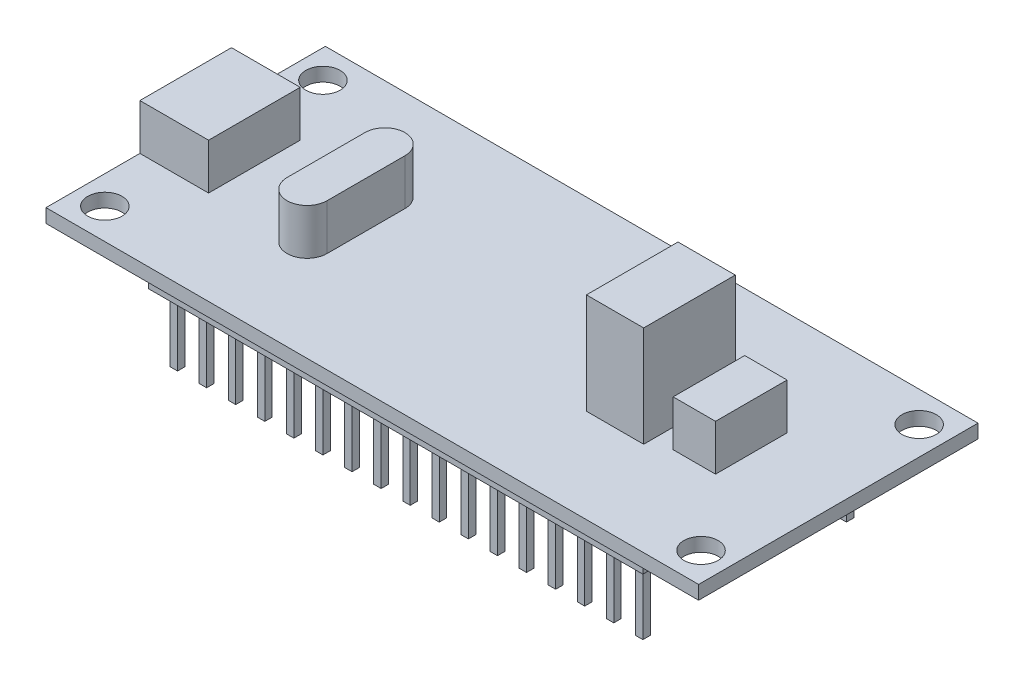
from build123d import *

# Parameters (mm, degrees)
SKETCH1_W           = 57
SKETCH1_H           = 24.4
BOSS_EXTRUDE1_DEPTH = 1.2
SKETCH2_R           = 1.5
CUT_EXTRUDE1_DEPTH  = 2.2
SKETCH3_W           = 6
SKETCH3_H           = 8
BOSS_EXTRUDE2_DEPTH = 4
BOSS_EXTRUDE3_DEPTH = 4
SKETCH5_W           = 5
SKETCH5_H           = 8
BOSS_EXTRUDE4_DEPTH = 8.8
SKETCH6_W           = 3.7
SKETCH6_H           = 6.25
BOSS_EXTRUDE5_DEPTH = 4
SKETCH7_W           = 43.18
SKETCH7_H           = 2.54
BOSS_EXTRUDE6_DEPTH = 2.5
SKETCH8_W           = 0.65
SKETCH8_H           = 0.65
BOSS_EXTRUDE7_DEPTH = 5.9


with BuildPart() as part:
    # Sketch1 → Boss-Extrude1 (new body)
    with BuildSketch(Plane(origin=(0, 0, 0), x_dir=(1, 0, 0), z_dir=(0, 1, 0))):
        Rectangle(SKETCH1_W, SKETCH1_H)
    extrude(amount=BOSS_EXTRUDE1_DEPTH)

    # Sketch2 → Cut-Extrude1 (cut, through all)
    with BuildSketch(Plane(origin=(0, 1.2, 0), x_dir=(1, 0, 0), z_dir=(0, 1, 0))):
        with Locations((-26.035, -9.525)):
            Circle(SKETCH2_R)
        with Locations((26.035, -9.525)):
            Circle(SKETCH2_R)
        with Locations((26.035, 9.525)):
            Circle(SKETCH2_R)
        with Locations((-26.035, 9.525)):
            Circle(SKETCH2_R)
    extrude(amount=-CUT_EXTRUDE1_DEPTH, mode=Mode.SUBTRACT)

    # Sketch3 → Boss-Extrude2 (add)
    with BuildSketch(Plane(origin=(0, 1.2, 0), x_dir=(1, 0, 0), z_dir=(0, 1, 0))):
        with Locations((-25.5, 0)):
            Rectangle(SKETCH3_W, SKETCH3_H)
    extrude(amount=BOSS_EXTRUDE2_DEPTH)

    # Sketch4 → Boss-Extrude3 (add)
    with BuildSketch(Plane(origin=(0, 1.2, 0), x_dir=(1, 0, 0), z_dir=(0, 1, 0))):
        with BuildLine():
            Line((-16.25, -3.4), (-16.25, 3.4))
            ThreePointArc((-16.25, 3.4), (-14.5, 5.15), (-12.75, 3.4))
            Line((-12.75, 3.4), (-12.75, -3.4))
            ThreePointArc((-12.75, -3.4), (-14.5, -5.15), (-16.25, -3.4))
        make_face()
    extrude(amount=BOSS_EXTRUDE3_DEPTH)

    # Sketch5 → Boss-Extrude4 (add)
    with BuildSketch(Plane(origin=(0, 1.2, 0), x_dir=(1, 0, 0), z_dir=(0, 1, 0))):
        with Locations((13, 0)):
            Rectangle(SKETCH5_W, SKETCH5_H)
    extrude(amount=BOSS_EXTRUDE4_DEPTH)

    # Sketch6 → Boss-Extrude5 (add)
    with BuildSketch(Plane(origin=(0, 1.2, 0), x_dir=(1, 0, 0), z_dir=(0, 1, 0))):
        with Locations((19.05, 0)):
            Rectangle(SKETCH6_W, SKETCH6_H)
    extrude(amount=BOSS_EXTRUDE5_DEPTH)

    # Sketch7 → Boss-Extrude6 (add)
    with BuildSketch(Plane.XZ):
        with Locations((0, 8.89)):
            Rectangle(SKETCH7_W, SKETCH7_H)
        with Locations((0, -8.89)):
            Rectangle(SKETCH7_W, SKETCH7_H)
    extrude(amount=BOSS_EXTRUDE6_DEPTH)

    # Sketch8 → Boss-Extrude7 (add)
    with BuildSketch(Plane.XZ.offset(2.5)):
        with Locations((-17.78, 8.89)):
            Rectangle(SKETCH8_W, SKETCH8_H)
        with Locations((-20.32, 8.89)):
            Rectangle(SKETCH8_W, SKETCH8_H)
        with Locations((-15.24, 8.89)):
            Rectangle(SKETCH8_W, SKETCH8_H)
        with Locations((-12.7, 8.89)):
            Rectangle(SKETCH8_W, SKETCH8_H)
        with Locations((-10.16, 8.89)):
            Rectangle(SKETCH8_W, SKETCH8_H)
        with Locations((-7.62, 8.89)):
            Rectangle(SKETCH8_W, SKETCH8_H)
        with Locations((-5.08, 8.89)):
            Rectangle(SKETCH8_W, SKETCH8_H)
        with Locations((-2.54, 8.89)):
            Rectangle(SKETCH8_W, SKETCH8_H)
        with Locations((0, 8.89)):
            Rectangle(SKETCH8_W, SKETCH8_H)
        with Locations((2.54, 8.89)):
            Rectangle(SKETCH8_W, SKETCH8_H)
        with Locations((5.08, 8.89)):
            Rectangle(SKETCH8_W, SKETCH8_H)
        with Locations((7.62, 8.89)):
            Rectangle(SKETCH8_W, SKETCH8_H)
        with Locations((10.16, 8.89)):
            Rectangle(SKETCH8_W, SKETCH8_H)
        with Locations((12.7, 8.89)):
            Rectangle(SKETCH8_W, SKETCH8_H)
        with Locations((15.24, 8.89)):
            Rectangle(SKETCH8_W, SKETCH8_H)
        with Locations((17.78, 8.89)):
            Rectangle(SKETCH8_W, SKETCH8_H)
        with Locations((20.32, 8.89)):
            Rectangle(SKETCH8_W, SKETCH8_H)
        with Locations((20.32, -8.89)):
            Rectangle(SKETCH8_W, SKETCH8_H)
        with Locations((17.78, -8.89)):
            Rectangle(SKETCH8_W, SKETCH8_H)
        with Locations((15.24, -8.89)):
            Rectangle(SKETCH8_W, SKETCH8_H)
        with Locations((12.7, -8.89)):
            Rectangle(SKETCH8_W, SKETCH8_H)
        with Locations((10.16, -8.89)):
            Rectangle(SKETCH8_W, SKETCH8_H)
        with Locations((7.62, -8.89)):
            Rectangle(SKETCH8_W, SKETCH8_H)
        with Locations((5.08, -8.89)):
            Rectangle(SKETCH8_W, SKETCH8_H)
        with Locations((2.54, -8.89)):
            Rectangle(SKETCH8_W, SKETCH8_H)
        with Locations((0, -8.89)):
            Rectangle(SKETCH8_W, SKETCH8_H)
        with Locations((-2.54, -8.89)):
            Rectangle(SKETCH8_W, SKETCH8_H)
        with Locations((-5.08, -8.89)):
            Rectangle(SKETCH8_W, SKETCH8_H)
        with Locations((-7.62, -8.89)):
            Rectangle(SKETCH8_W, SKETCH8_H)
        with Locations((-10.16, -8.89)):
            Rectangle(SKETCH8_W, SKETCH8_H)
        with Locations((-12.7, -8.89)):
            Rectangle(SKETCH8_W, SKETCH8_H)
        with Locations((-15.24, -8.89)):
            Rectangle(SKETCH8_W, SKETCH8_H)
        with Locations((-17.78, -8.89)):
            Rectangle(SKETCH8_W, SKETCH8_H)
        with Locations((-20.32, -8.89)):
            Rectangle(SKETCH8_W, SKETCH8_H)
    extrude(amount=BOSS_EXTRUDE7_DEPTH)


solid = part.part
